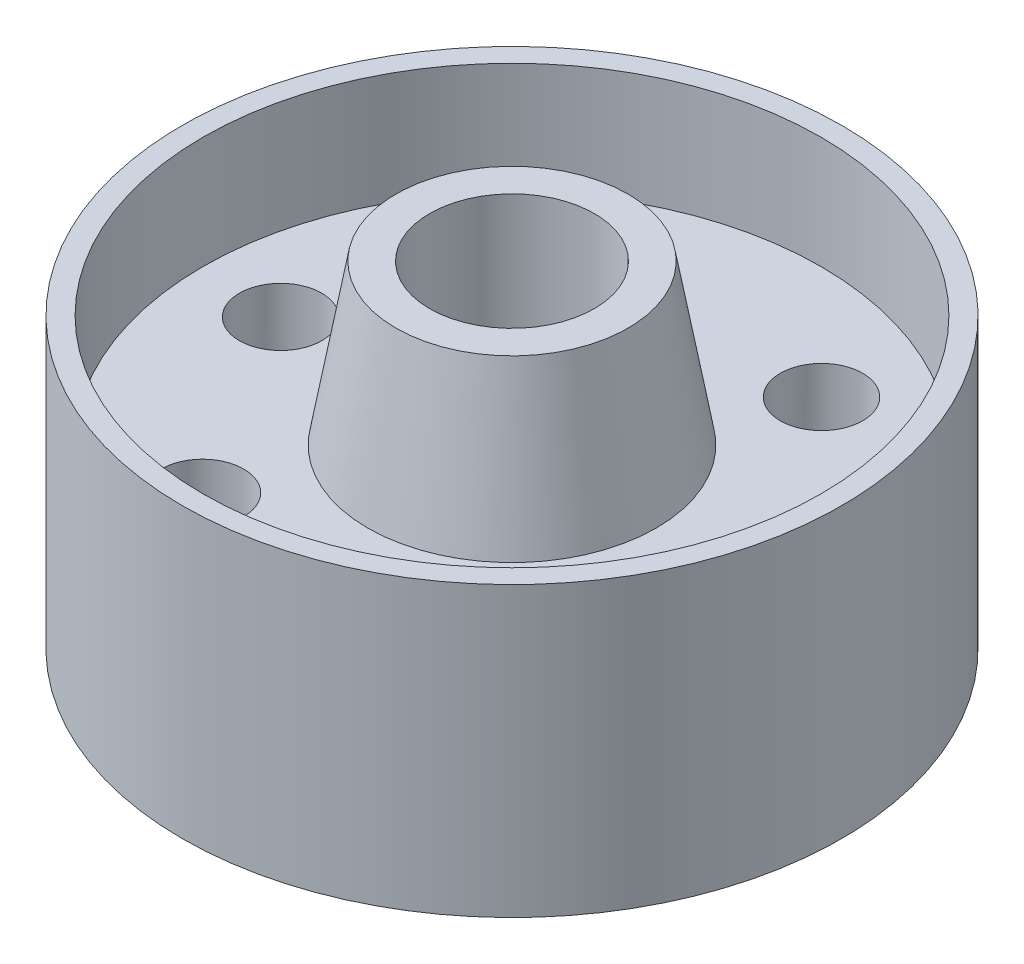
from build123d import *

# Parameters (mm, degrees)
F_1_4_0_5_DIAMETER_HOLE2_D = 12.7


with BuildPart() as part:
    # Sketch1 → Revolve3 (revolve)
    with BuildSketch(Plane(origin=(0, 0, 0), x_dir=(0, 0, -1), z_dir=(1, 0, 0))):
        Polygon((-38.1, 0), (-38.1, 22.098), (-34.925, 22.098), (-34.925, 4.826), (-9.525, 4.826), (-5.198570671, 29.3624), (0, 29.3624), (0, -29.3624), (-5.198570671, -29.3624), (-9.525, -4.826), (-34.925, -4.826), (-34.925, -22.352), (-38.1, -22.352), align=None)
    revolve(axis=Axis((0, 29.3624, -12.7), (0, -1, 0)))

    # 1_4 _0.5_ Diameter Hole2 (through all)
    with Locations(Plane(origin=(0, 4.826, 0), x_dir=(1, 0, 0), z_dir=(0, 1, 0))):
        with Locations((-17.4625, 42.945937227), (17.4625, 42.945937227), (34.91559931, 11.889722379), (17.4625, -17.545937227), (-17.4625, -17.545937227), (-34.916879179, 11.946890841)):
            Hole(F_1_4_0_5_DIAMETER_HOLE2_D / 2)


solid = part.part
